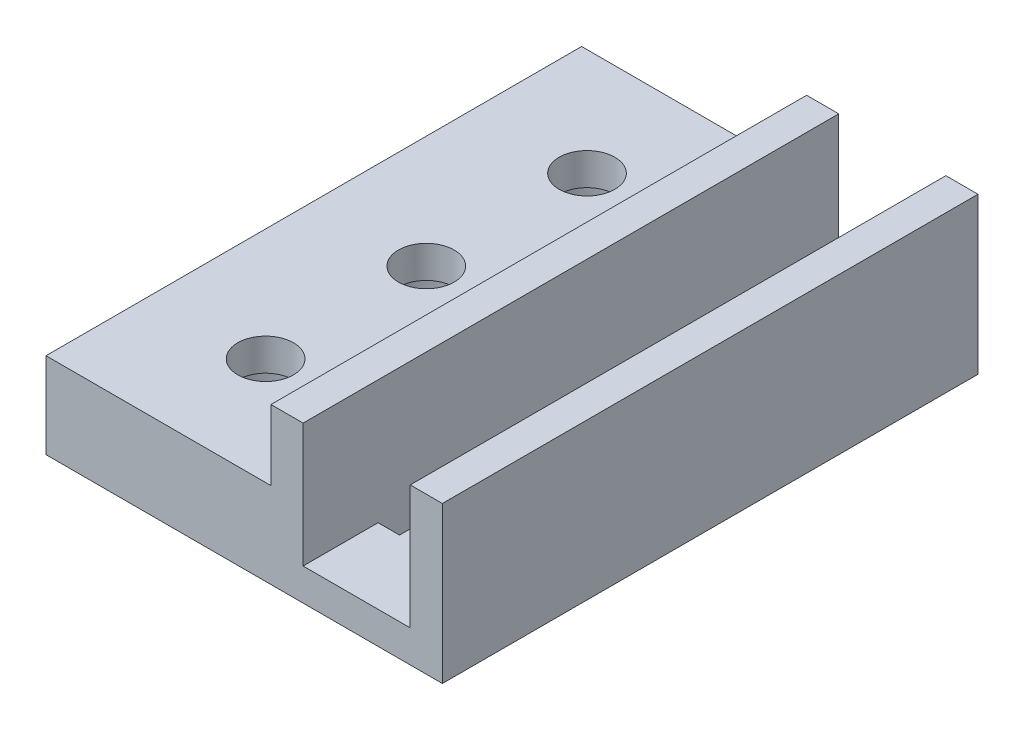
from build123d import *

# Parameters (mm, degrees)
SKETCH1_W           = 21
SKETCH1_H           = 50
SKETCH1_R           = 2.6
BOSS_EXTRUDE1_DEPTH = 8
SKETCH2_R           = 5.5
CUT_EXTRUDE1_DEPTH  = 5
BOSS_EXTRUDE2_DEPTH = 50
CUT_EXTRUDE2_REACH  = 5
SKETCH4_W           = 2
SKETCH4_H           = 5


with BuildPart() as part:
    # Sketch1 → Boss-Extrude1 (new body)
    with BuildSketch(Plane(origin=(0, 0, 0), x_dir=(1, 0, 0), z_dir=(0, 1, 0))):
        Rectangle(SKETCH1_W, SKETCH1_H)
        with Locations((0, -15)):
            Circle(SKETCH1_R, mode=Mode.SUBTRACT)
        Circle(SKETCH1_R, mode=Mode.SUBTRACT)
        with Locations((0, 15)):
            Circle(SKETCH1_R, mode=Mode.SUBTRACT)
    extrude(amount=BOSS_EXTRUDE1_DEPTH)

    # Sketch2 → Cut-Extrude1 (cut)
    with BuildSketch(Plane.XZ):
        Circle(SKETCH2_R)
        with Locations((0, 15)):
            Circle(SKETCH2_R)
        with Locations((0, -15)):
            Circle(SKETCH2_R)
    extrude(amount=-CUT_EXTRUDE1_DEPTH, mode=Mode.SUBTRACT)

    # Sketch3 → Boss-Extrude2 (add)
    with BuildSketch(Plane.XY.offset(25)):
        Polygon((10.5, 8), (10.5, 0), (26.5, 0), (26.5, 14.555402141), (23.5, 14.555402141), (23.5, 3), (13.5, 3), (13.5, 14.555402141), (10.5, 14.555402141), align=None)
    extrude(amount=-BOSS_EXTRUDE2_DEPTH)

    # Sketch4 → Cut-Extrude2 (cut, up to next)
    with BuildSketch(Plane(origin=(0, 3, 0), x_dir=(1, 0, 0), z_dir=(0, 1, 0)), mode=Mode.PRIVATE) as cut_extrude2_sk1:
        with Locations((14.5, -15.5)):
            Rectangle(SKETCH4_W, SKETCH4_H)
    cut_extrude2_tool1 = extrude(cut_extrude2_sk1.sketch, amount=-CUT_EXTRUDE2_REACH, mode=Mode.PRIVATE) & part.part
    add(cut_extrude2_tool1.solids().sort_by_distance((14.5, 3, 15.5))[0], mode=Mode.SUBTRACT)
    # Sketch4 → Cut-Extrude2 (cut, up to next)
    with BuildSketch(Plane(origin=(0, 3, 0), x_dir=(1, 0, 0), z_dir=(0, 1, 0)), mode=Mode.PRIVATE) as cut_extrude2_sk2:
        with Locations((14.5, 15.5)):
            Rectangle(SKETCH4_W, SKETCH4_H)
    cut_extrude2_tool2 = extrude(cut_extrude2_sk2.sketch, amount=-CUT_EXTRUDE2_REACH, mode=Mode.PRIVATE) & part.part
    add(cut_extrude2_tool2.solids().sort_by_distance((14.5, 3, -15.5))[0], mode=Mode.SUBTRACT)
    # Sketch4 → Cut-Extrude2 (cut, up to next)
    with BuildSketch(Plane(origin=(0, 3, 0), x_dir=(1, 0, 0), z_dir=(0, 1, 0)), mode=Mode.PRIVATE) as cut_extrude2_sk3:
        with Locations((22.5, 0)):
            Rectangle(SKETCH4_W, SKETCH4_H)
    cut_extrude2_tool3 = extrude(cut_extrude2_sk3.sketch, amount=-CUT_EXTRUDE2_REACH, mode=Mode.PRIVATE) & part.part
    add(cut_extrude2_tool3.solids().sort_by_distance((22.5, 3, 0))[0], mode=Mode.SUBTRACT)
    # Sketch4 → Cut-Extrude2 (cut, up to next)
    with BuildSketch(Plane(origin=(0, 3, 0), x_dir=(1, 0, 0), z_dir=(0, 1, 0)), mode=Mode.PRIVATE) as cut_extrude2_sk4:
        with Locations((14.5, 0)):
            Rectangle(SKETCH4_W, SKETCH4_H)
    cut_extrude2_tool4 = extrude(cut_extrude2_sk4.sketch, amount=-CUT_EXTRUDE2_REACH, mode=Mode.PRIVATE) & part.part
    add(cut_extrude2_tool4.solids().sort_by_distance((14.5, 3, 0))[0], mode=Mode.SUBTRACT)
    # Sketch4 → Cut-Extrude2 (cut, up to next)
    with BuildSketch(Plane(origin=(0, 3, 0), x_dir=(1, 0, 0), z_dir=(0, 1, 0)), mode=Mode.PRIVATE) as cut_extrude2_sk5:
        with Locations((22.5, 15.5)):
            Rectangle(SKETCH4_W, SKETCH4_H)
    cut_extrude2_tool5 = extrude(cut_extrude2_sk5.sketch, amount=-CUT_EXTRUDE2_REACH, mode=Mode.PRIVATE) & part.part
    add(cut_extrude2_tool5.solids().sort_by_distance((22.5, 3, -15.5))[0], mode=Mode.SUBTRACT)
    # Sketch4 → Cut-Extrude2 (cut, up to next)
    with BuildSketch(Plane(origin=(0, 3, 0), x_dir=(1, 0, 0), z_dir=(0, 1, 0)), mode=Mode.PRIVATE) as cut_extrude2_sk6:
        with Locations((22.5, -15.5)):
            Rectangle(SKETCH4_W, SKETCH4_H)
    cut_extrude2_tool6 = extrude(cut_extrude2_sk6.sketch, amount=-CUT_EXTRUDE2_REACH, mode=Mode.PRIVATE) & part.part
    add(cut_extrude2_tool6.solids().sort_by_distance((22.5, 3, 15.5))[0], mode=Mode.SUBTRACT)


solid = part.part
